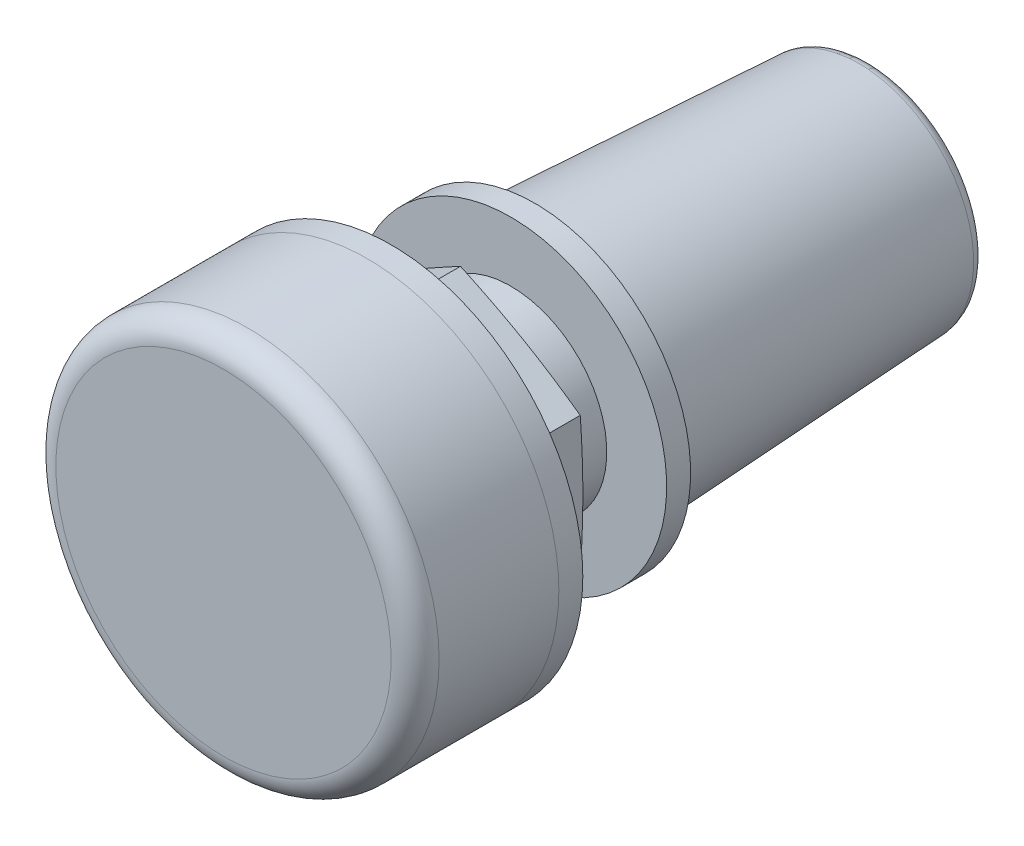
from build123d import *

# Parameters (mm, degrees)
ESQUISSE1_R             = 8
BOSS_EXTRU_1_DEPTH      = 6
CONG_1_R                = 1
ESQUISSE2_R             = 8
BOSS_EXTRU_2_DEPTH      = 1
ESQUISSE3_R             = 4
BOSS_EXTRU_3_DEPTH      = 5
ESQUISSE4_R             = 6.5
BOSS_EXTRU_4_DEPTH      = 1
ESQUISSE5_R             = 5.5
BOSS_EXTRU_5_DEPTH      = 14
BOSS_EXTRU_5_TAPER      = 3
CONG_2_R                = 0.5
BOSS_EXTRU_6_START      = 1.5
BOSS_EXTRU_6_DEPTH      = 1.5
ESQUISSE8_OUTSIDE_W     = 46.392
ESQUISSE8_OUTSIDE_H     = 46.392
ESQUISSE8_OUTSIDE_R     = 5
ENL_V_MAT_EXTRU_3_DEPTH = 1.5
ENL_V_MAT_EXTRU_3_TAPER = 82
ESQUISSE9_OUTSIDE_W     = 46.392
ESQUISSE9_OUTSIDE_H     = 46.392
ESQUISSE9_OUTSIDE_R     = 5
ENL_V_MAT_EXTRU_4_DEPTH = 1.5
ENL_V_MAT_EXTRU_4_TAPER = 82


with BuildPart() as part:
    # Esquisse1 → Boss.-Extru.1 (new body)
    with BuildSketch(Plane.XY):
        Circle(ESQUISSE1_R)
    extrude(amount=BOSS_EXTRU_1_DEPTH)

    # Congé1
    cong_1_edges = [part.edges().sort_by_distance(p)[0] for p in [
        (-8, 0, 6),
    ]]
    fillet(cong_1_edges, radius=CONG_1_R)


with BuildPart() as body_2:
    # Esquisse2 → Boss.-Extru.2 (new body)
    with BuildSketch(Plane(origin=(0, 0, 0), x_dir=(-1, 0, 0), z_dir=(0, 0, -1))):
        Circle(ESQUISSE2_R)
    extrude(amount=BOSS_EXTRU_2_DEPTH)


with BuildPart() as body_3:
    # Esquisse3 → Boss.-Extru.3 (new body)
    with BuildSketch(Plane(origin=(0, 0, -1), x_dir=(-1, 0, 0), z_dir=(0, 0, -1))):
        Circle(ESQUISSE3_R)
    extrude(amount=BOSS_EXTRU_3_DEPTH)

    # Esquisse4 → Boss.-Extru.4 (add)
    with BuildSketch(Plane(origin=(0, 0, -6), x_dir=(-1, 0, 0), z_dir=(0, 0, -1))):
        Circle(ESQUISSE4_R)
    extrude(amount=BOSS_EXTRU_4_DEPTH)

    # Esquisse5 → Boss.-Extru.5 (add)
    with BuildSketch(Plane(origin=(0, 0, -7), x_dir=(-1, 0, 0), z_dir=(0, 0, -1))):
        Circle(ESQUISSE5_R)
    extrude(amount=BOSS_EXTRU_5_DEPTH, taper=BOSS_EXTRU_5_TAPER)

    # Congé2
    cong_2_edges = [body_3.edges().sort_by_distance(p)[0] for p in [
        (4.76629109, 0, -21),
    ]]
    fillet(cong_2_edges, radius=CONG_2_R)


with BuildPart() as body_4:
    # Esquisse7 → Boss.-Extru.6 (new body)
    with BuildSketch(Plane(origin=(0, 0, -1), x_dir=(-1, 0, 0), z_dir=(0, 0, -1)).offset(BOSS_EXTRU_6_START)):
        Polygon((-5, 2.886751346), (-5, -2.886751346), (0, -5.773502692), (5, -2.886751346), (5, 2.886751346), (0, 5.773502692), align=None)
    extrude(amount=BOSS_EXTRU_6_DEPTH)

    # Esquisse8 outside → Enlèv. mat.-Extru.3 (cut)
    with BuildSketch(Plane(origin=(0, 0, -4), x_dir=(-1, 0, 0), z_dir=(0, 0, -1))):
        Rectangle(ESQUISSE8_OUTSIDE_W, ESQUISSE8_OUTSIDE_H)
        Circle(ESQUISSE8_OUTSIDE_R, mode=Mode.SUBTRACT)
    extrude(amount=-ENL_V_MAT_EXTRU_3_DEPTH, taper=ENL_V_MAT_EXTRU_3_TAPER, mode=Mode.SUBTRACT)

    # Esquisse9 outside → Enlèv. mat.-Extru.4 (cut)
    with BuildSketch(Plane.XY.offset(-2.5)):
        Rectangle(ESQUISSE9_OUTSIDE_W, ESQUISSE9_OUTSIDE_H)
        Circle(ESQUISSE9_OUTSIDE_R, mode=Mode.SUBTRACT)
    extrude(amount=-ENL_V_MAT_EXTRU_4_DEPTH, taper=ENL_V_MAT_EXTRU_4_TAPER, mode=Mode.SUBTRACT)


solid = Compound([part.part, body_2.part, body_3.part, body_4.part])
